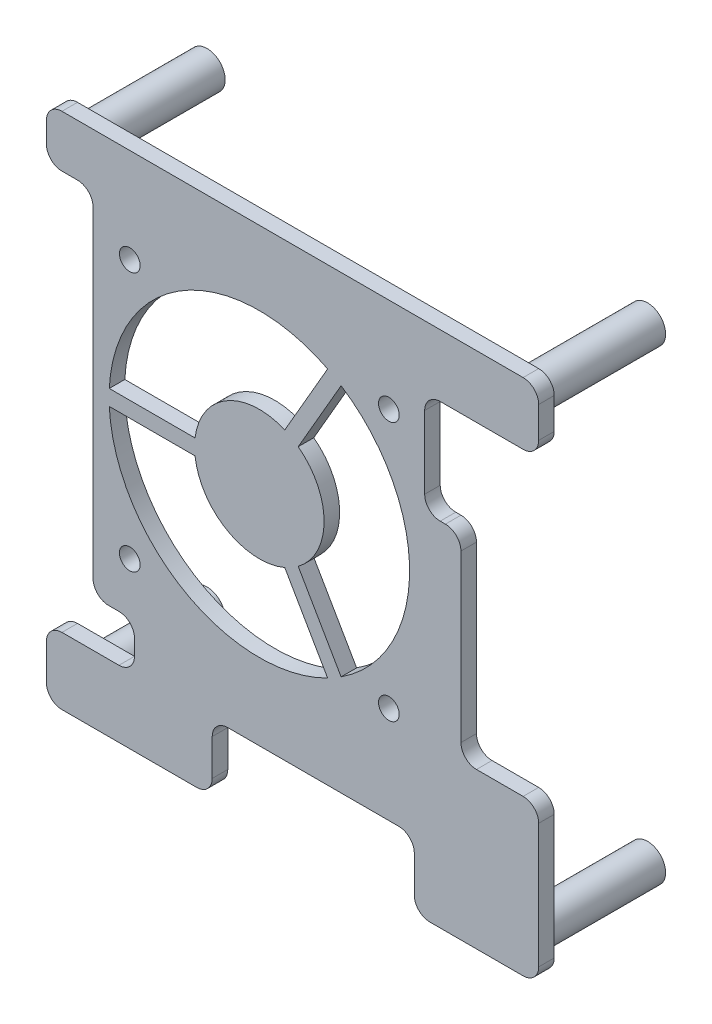
from build123d import *

# Parameters (mm, degrees)
SALIENTE_EXTRUIR1_DEPTH = 3
CROQUIS2_R              = 3.5
CROQUIS2_R_2            = 1.5
SALIENTE_EXTRUIR2_DEPTH = 23
CROQUIS3_R              = 2
CORTAR_EXTRUIR1_DEPTH   = 3


with BuildPart() as part:
    # Croquis1 → Saliente-Extruir1 (new body)
    with BuildSketch(Plane.XY):
        with BuildLine():
            Line((-194.10496046, 92.470884256), (-194.10496046, 88.470884256))
            ThreePointArc((-194.10496046, 88.470884256), (-193.226280804, 86.349563912), (-191.10496046, 85.470884256))
            Line((-191.10496046, 85.470884256), (-188.10496046, 85.470884256))
            ThreePointArc((-188.10496046, 85.470884256), (-185.983640117, 84.592204599), (-185.10496046, 82.470884256))
            Line((-185.10496046, 82.470884256), (-185.10496046, 20.382772077))
            ThreePointArc((-185.10496046, 20.382772077), (-184.226280804, 18.261451734), (-182.10496046, 17.382772077))
            Line((-182.10496046, 17.382772077), (-180.10496046, 17.382772077))
            ThreePointArc((-180.10496046, 17.382772077), (-177.983640117, 16.504092421), (-177.10496046, 14.382772077))
            Line((-177.10496046, 14.382772077), (-177.10496046, 11.382772077))
            ThreePointArc((-177.10496046, 11.382772077), (-177.983640117, 9.261451734), (-180.10496046, 8.382772077))
            Line((-180.10496046, 8.382772077), (-191.10496046, 8.382772077))
            ThreePointArc((-191.10496046, 8.382772077), (-193.226280804, 7.504092421), (-194.10496046, 5.382772077))
            Line((-194.10496046, 5.382772077), (-194.10496046, -1.529115744))
            ThreePointArc((-194.10496046, -1.529115744), (-193.226280804, -3.650436088), (-191.10496046, -4.529115744))
            Line((-191.10496046, -4.529115744), (-165.10496046, -4.529115744))
            ThreePointArc((-165.10496046, -4.529115744), (-162.983640117, -3.650436088), (-162.10496046, -1.529115744))
            Line((-162.10496046, -1.529115744), (-162.10496046, 5.470884256))
            ThreePointArc((-162.10496046, 5.470884256), (-161.226280804, 7.592204599), (-159.10496046, 8.470884256))
            Line((-159.10496046, 8.470884256), (-126.10496046, 8.470884256))
            ThreePointArc((-126.10496046, 8.470884256), (-123.983640117, 7.592204599), (-123.10496046, 5.470884256))
            Line((-123.10496046, 5.470884256), (-123.10496046, -1.529115744))
            ThreePointArc((-123.10496046, -1.529115744), (-122.226280804, -3.650436088), (-120.10496046, -4.529115744))
            Line((-120.10496046, -4.529115744), (-102.10496046, -4.529115744))
            ThreePointArc((-102.10496046, -4.529115744), (-99.983640117, -3.650436088), (-99.10496046, -1.529115744))
            Line((-99.10496046, -1.529115744), (-99.10496046, 22.470884256))
            ThreePointArc((-99.10496046, 22.470884256), (-99.983640117, 24.592204599), (-102.10496046, 25.470884256))
            Line((-102.10496046, 25.470884256), (-111.10496046, 25.470884256))
            ThreePointArc((-111.10496046, 25.470884256), (-113.226280804, 26.349563912), (-114.10496046, 28.470884256))
            Line((-114.10496046, 28.470884256), (-114.10496046, 60.470884256))
            ThreePointArc((-114.10496046, 60.470884256), (-114.983640117, 62.592204599), (-117.10496046, 63.470884256))
            Line((-117.10496046, 63.470884256), (-118.10496046, 63.470884256))
            ThreePointArc((-118.10496046, 63.470884256), (-120.226280804, 64.349563912), (-121.10496046, 66.470884256))
            Line((-121.10496046, 66.470884256), (-121.10496046, 80.470884256))
            ThreePointArc((-121.10496046, 80.470884256), (-120.226280804, 82.592204599), (-118.10496046, 83.470884256))
            Line((-118.10496046, 83.470884256), (-102.10496046, 83.470884256))
            ThreePointArc((-102.10496046, 83.470884256), (-99.983640117, 84.349563912), (-99.10496046, 86.470884256))
            Line((-99.10496046, 86.470884256), (-99.10496046, 92.470884256))
            ThreePointArc((-99.10496046, 92.470884256), (-99.983640117, 94.592204599), (-102.10496046, 95.470884256))
            Line((-102.10496046, 95.470884256), (-191.10496046, 95.470884256))
            ThreePointArc((-191.10496046, 95.470884256), (-193.226280804, 94.592204599), (-194.10496046, 92.470884256))
        make_face()
        with BuildLine():
            Line((-165.422187349, 50.715677144), (-181.973694619, 50.715677144))
            ThreePointArc((-181.973694619, 50.715677144), (-167.512513703, 27.100940434), (-139.830961352, 26.384558748))
            Line((-139.830961352, 26.384558748), (-148.106714986, 40.718584514))
            ThreePointArc((-148.106714986, 40.718584514), (-159.262513703, 41.390359596), (-165.422187349, 50.715677144))
        make_face(mode=Mode.SUBTRACT)
        with BuildLine():
            Line((-165.422187349, 53.715677144), (-181.973694619, 53.715677144))
            ThreePointArc((-181.973694619, 53.715677144), (-167.512513703, 77.330413853), (-139.830961352, 78.04679554))
            Line((-139.830961352, 78.04679554), (-148.106714986, 63.712769774))
            ThreePointArc((-148.106714986, 63.712769774), (-159.262513703, 63.040994691), (-165.422187349, 53.715677144))
        make_face(mode=Mode.SUBTRACT)
        with BuildLine():
            Line((-145.508638775, 62.212769774), (-137.23288514, 76.54679554))
            ThreePointArc((-137.23288514, 76.54679554), (-124.012513703, 52.215677144), (-137.23288514, 27.884558748))
            Line((-137.23288514, 27.884558748), (-145.508638775, 42.218584514))
            ThreePointArc((-145.508638775, 42.218584514), (-140.512513703, 52.215677144), (-145.508638775, 62.212769774))
        make_face(mode=Mode.SUBTRACT)
    extrude(amount=SALIENTE_EXTRUIR1_DEPTH)

    # Croquis2 → Saliente-Extruir2 (add)
    with BuildSketch(Plane(origin=(0, 0, 0), x_dir=(-1, 0, 0), z_dir=(0, 0, -1))):
        with Locations((189.10496046, 90.470884256)):
            Circle(CROQUIS2_R)
        with Locations((189.10496046, 90.470884256)):
            Circle(CROQUIS2_R_2, mode=Mode.SUBTRACT)
        with Locations((104.10496046, 90.470884256)):
            Circle(CROQUIS2_R)
        with Locations((104.10496046, 90.470884256)):
            Circle(CROQUIS2_R_2, mode=Mode.SUBTRACT)
        with Locations((104.10496046, 0.470884256)):
            Circle(CROQUIS2_R)
        with Locations((104.10496046, 0.470884256)):
            Circle(CROQUIS2_R_2, mode=Mode.SUBTRACT)
        with Locations((189.10496046, 0.470884256)):
            Circle(CROQUIS2_R)
        with Locations((189.10496046, 0.470884256)):
            Circle(CROQUIS2_R_2, mode=Mode.SUBTRACT)
    extrude(amount=SALIENTE_EXTRUIR2_DEPTH)

    # Croquis3 → Cortar-Extruir1 (cut)
    with BuildSketch(Plane.XY.offset(3)):
        with Locations((-178.012513703, 77.215677144)):
            Circle(CROQUIS3_R)
        with Locations((-128.012513703, 77.215677144)):
            Circle(CROQUIS3_R)
        with Locations((-128.012513703, 27.215677144)):
            Circle(CROQUIS3_R)
        with Locations((-178.012513703, 27.215677144)):
            Circle(CROQUIS3_R)
    extrude(amount=-CORTAR_EXTRUIR1_DEPTH, mode=Mode.SUBTRACT)


solid = part.part
